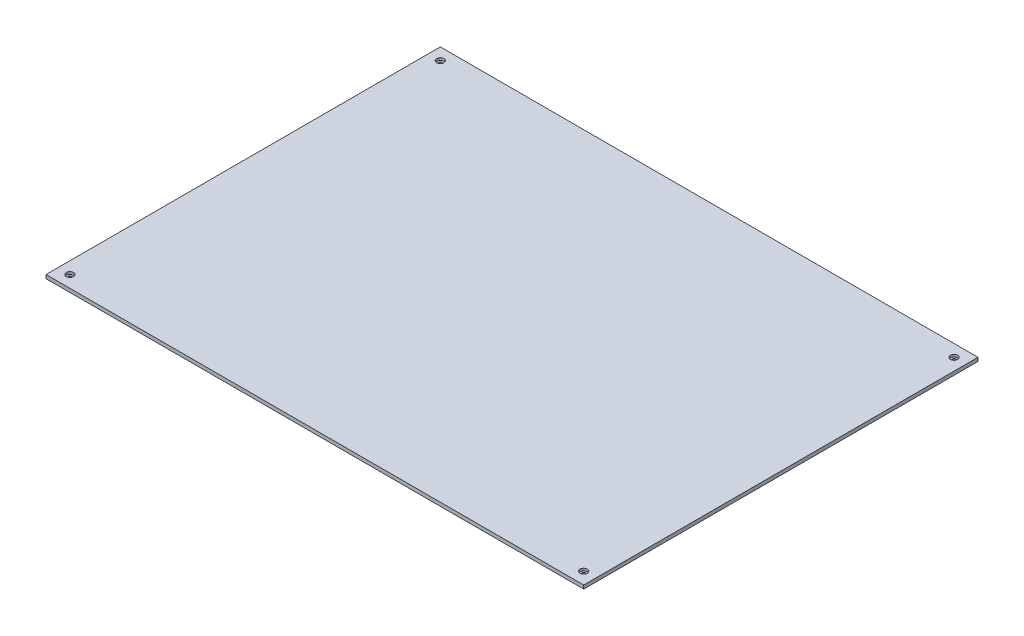
from build123d import *

# Parameters (mm, degrees)
SKETCH1_W           = 450
SKETCH1_H           = 330
SKETCH1_R           = 3.05
SKETCH1_R_2         = 1.55
BOSS_EXTRUDE1_DEPTH = 3
CUT_EXTRUDE1_START  = 3
SKETCH1_3_R         = 3.05
SKETCH1_3_R_2       = 1.55
CUT_EXTRUDE1_DEPTH  = 2


with BuildPart() as part:
    # Sketch1 → Boss-Extrude1 (new body)
    with BuildSketch(Plane(origin=(0, 0, 0), x_dir=(1, 0, 0), z_dir=(0, 1, 0))):
        Rectangle(SKETCH1_W, SKETCH1_H)
        with Locations((215, -155)):
            Circle(SKETCH1_R, mode=Mode.SUBTRACT)
        with Locations((-215, 155)):
            Circle(SKETCH1_R, mode=Mode.SUBTRACT)
        with Locations((215, 155)):
            Circle(SKETCH1_R, mode=Mode.SUBTRACT)
        with Locations((-215, -155)):
            Circle(SKETCH1_R, mode=Mode.SUBTRACT)
        with Locations((-215, 155)):
            Circle(SKETCH1_R)
        with Locations((-215, 155)):
            Circle(SKETCH1_R_2, mode=Mode.SUBTRACT)
        with Locations((215, 155)):
            Circle(SKETCH1_R)
        with Locations((215, 155)):
            Circle(SKETCH1_R_2, mode=Mode.SUBTRACT)
        with Locations((215, -155)):
            Circle(SKETCH1_R)
        with Locations((215, -155)):
            Circle(SKETCH1_R_2, mode=Mode.SUBTRACT)
        with Locations((-215, -155)):
            Circle(SKETCH1_R)
        with Locations((-215, -155)):
            Circle(SKETCH1_R_2, mode=Mode.SUBTRACT)
    extrude(amount=BOSS_EXTRUDE1_DEPTH)

    # Sketch1_3 → Cut-Extrude1 (cut)
    with BuildSketch(Plane(origin=(0, 0, 0), x_dir=(1, 0, 0), z_dir=(0, 1, 0)).offset(CUT_EXTRUDE1_START)):
        with Locations((-215, -155)):
            Circle(SKETCH1_3_R)
        with Locations((-215, -155)):
            Circle(SKETCH1_3_R_2, mode=Mode.SUBTRACT)
        with Locations((-215, 155)):
            Circle(SKETCH1_3_R)
        with Locations((-215, 155)):
            Circle(SKETCH1_3_R_2, mode=Mode.SUBTRACT)
        with Locations((215, -155)):
            Circle(SKETCH1_3_R)
        with Locations((215, -155)):
            Circle(SKETCH1_3_R_2, mode=Mode.SUBTRACT)
        with Locations((215, 155)):
            Circle(SKETCH1_3_R)
        with Locations((215, 155)):
            Circle(SKETCH1_3_R_2, mode=Mode.SUBTRACT)
    extrude(amount=-CUT_EXTRUDE1_DEPTH, mode=Mode.SUBTRACT)


solid = part.part
